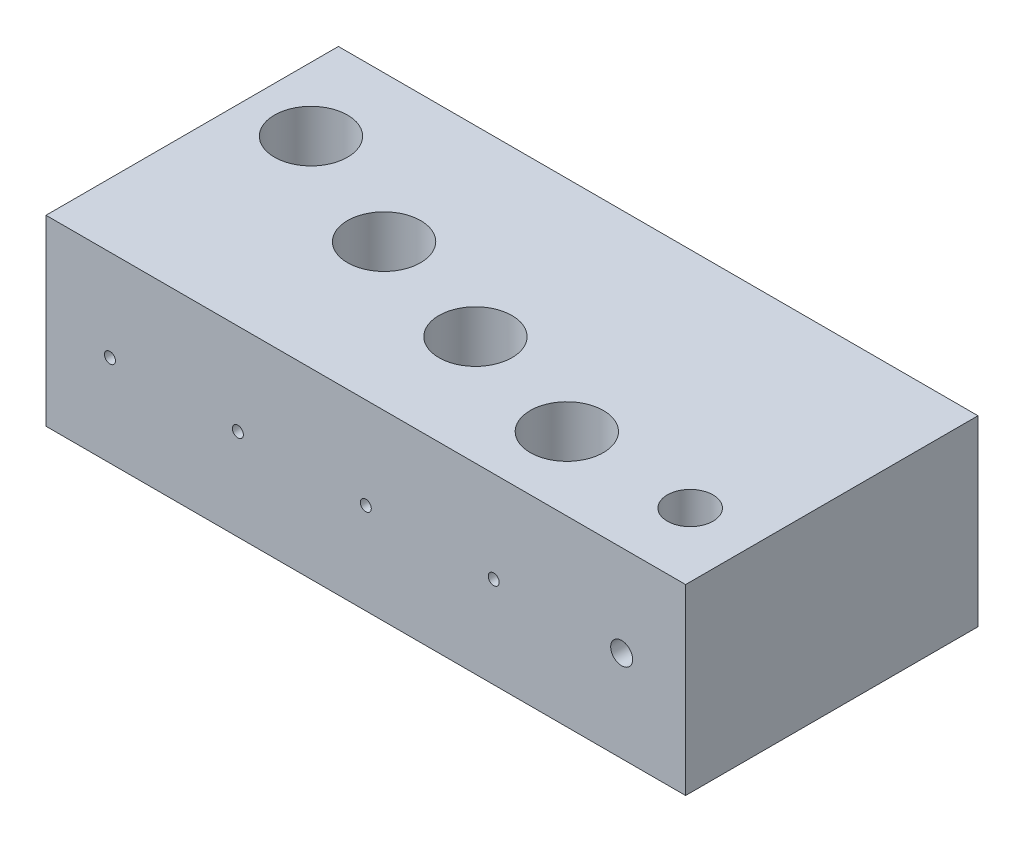
from build123d import *
from build123d.topology import SkipClean

# Parameters (mm, degrees)
SKETCH1_W           = 70
SKETCH1_H           = 20
BOSS_EXTRUDE1_DEPTH = 32
SKETCH3_R           = 1.2
CUT_EXTRUDE1_DEPTH  = 10
SKETCH3_3_R         = 0.6
CUT_EXTRUDE2_DEPTH  = 12
SKETCH3_4_R         = 0.6
CUT_EXTRUDE3_DEPTH  = 16
SKETCH3_5_R         = 0.6
CUT_EXTRUDE4_DEPTH  = 20
SKETCH3_6_R         = 0.6
CUT_EXTRUDE5_DEPTH  = 26
SKETCH4_R           = 2.5
SKETCH4_R_2         = 4
CUT_EXTRUDE6_DEPTH  = 15


with BuildPart() as part:
    # Sketch1 → Boss-Extrude1 (new body)
    with BuildSketch(Plane.XY):
        Rectangle(SKETCH1_W, SKETCH1_H)
    extrude(amount=BOSS_EXTRUDE1_DEPTH)

    # Sketch3 → Cut-Extrude1 (cut)
    with BuildSketch(Plane.XY.offset(32)):
        with Locations((28, 0)):
            Circle(SKETCH3_R)
    extrude(amount=-CUT_EXTRUDE1_DEPTH, mode=Mode.SUBTRACT)

    # Sketch3_3 → Cut-Extrude2 (cut)
    with BuildSketch(Plane.XY.offset(32)):
        with Locations((14, 0)):
            Circle(SKETCH3_3_R)
    extrude(amount=-CUT_EXTRUDE2_DEPTH, mode=Mode.SUBTRACT)

    # Sketch3_4 → Cut-Extrude3 (cut)
    with BuildSketch(Plane.XY.offset(32)):
        Circle(SKETCH3_4_R)
    extrude(amount=-CUT_EXTRUDE3_DEPTH, mode=Mode.SUBTRACT)

    # Sketch3_5 → Cut-Extrude4 (cut)
    with BuildSketch(Plane.XY.offset(32)):
        with Locations((-14, 0)):
            Circle(SKETCH3_5_R)
    extrude(amount=-CUT_EXTRUDE4_DEPTH, mode=Mode.SUBTRACT)

    # Sketch3_6 → Cut-Extrude5 (cut)
    with BuildSketch(Plane.XY.offset(32)):
        with Locations((-28, 0)):
            Circle(SKETCH3_6_R)
    extrude(amount=-CUT_EXTRUDE5_DEPTH, mode=Mode.SUBTRACT)

    # Sketch4 → Cut-Extrude6 (cut)
    with SkipClean():  # the faces are left unmerged after this step: merging them gives an invalid solid
        with BuildSketch(Plane(origin=(0, 10, 0), x_dir=(1, 0, 0), z_dir=(0, 1, 0))):
            with Locations((28, -24.5)):
                Circle(SKETCH4_R)
            with Locations((14, -24)):
                Circle(SKETCH4_R_2)
            with Locations((0, -20)):
                Circle(SKETCH4_R_2)
            with Locations((-14, -16)):
                Circle(SKETCH4_R_2)
            with Locations((-28, -10)):
                Circle(SKETCH4_R_2)
        extrude(amount=-CUT_EXTRUDE6_DEPTH, mode=Mode.SUBTRACT)


solid = part.part
